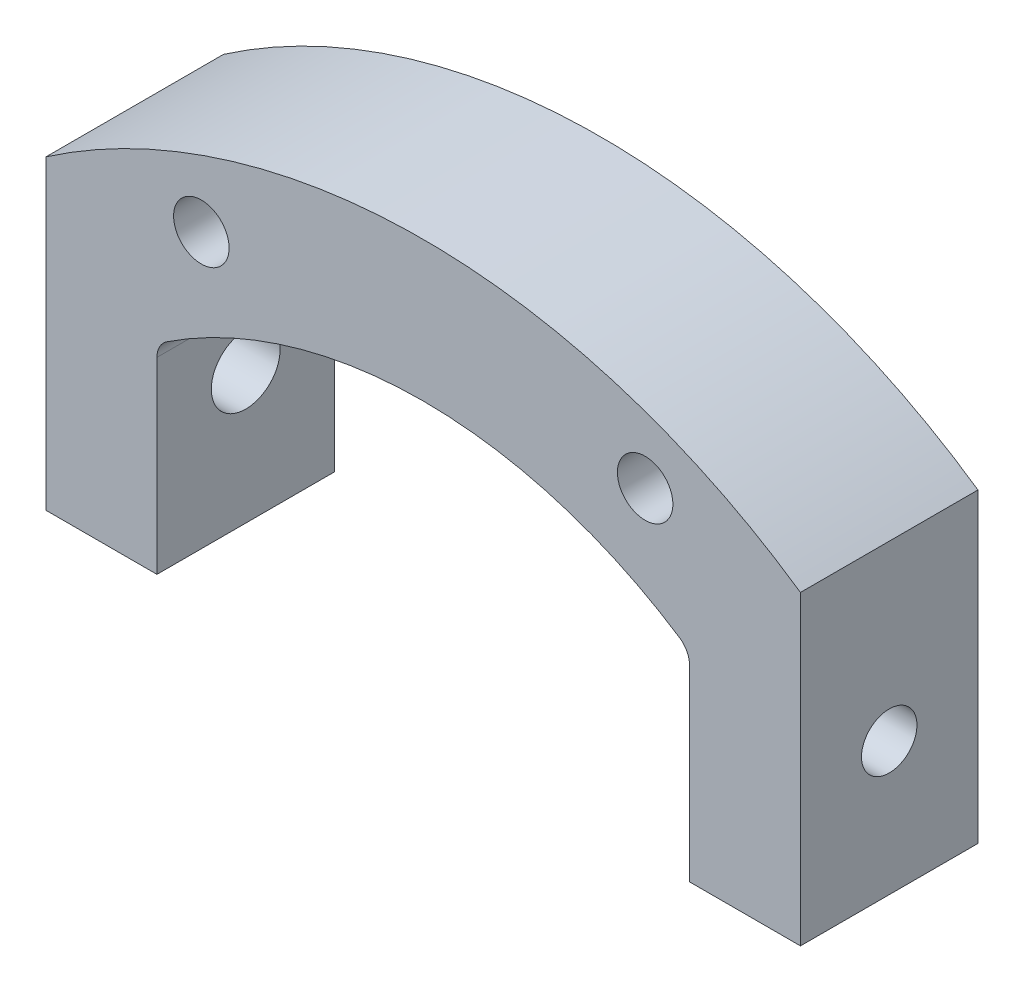
from build123d import *

# Parameters (mm, degrees)
SKETCH_4_R          = 1.25
EXTRUDE_2_DEPTH     = 8
SKETCH_5_W          = 4.5
SKETCH_5_H          = 18.121653049
CUT_EXTRUDE_2_DEPTH = 9
SKETCH_6_R          = 1.25
CUT_EXTRUDE_3_DEPTH = 35
SKETCH_7_R          = 1.55
CUT_EXTRUDE_4_DEPTH = 6
FILLET_1_R          = 1


with BuildPart() as part:
    # 草图4 → 凸台-拉伸2 (new body)
    with BuildSketch(Plane.XY):
        with BuildLine():
            Line((-21.5, 5), (-21.5, -5))
            Line((-21.5, -5), (21.5, -5))
            Line((21.5, -5), (21.5, 5))
            ThreePointArc((21.5, 5), (0, 14.077524047), (-21.5, 5))
        make_face()
        with Locations((-10, 9.361795295)):
            Circle(SKETCH_4_R, mode=Mode.SUBTRACT)
        with Locations((10, 9.361795295)):
            Circle(SKETCH_4_R, mode=Mode.SUBTRACT)
    extrude(amount=EXTRUDE_2_DEPTH)

    # 草图5 → 切除-拉伸2 (cut, through all)
    with BuildSketch(Plane.XY.offset(8)):
        with BuildLine():
            Line((-12, 4), (-12, -5))
            Line((-12, -5), (12, -5))
            Line((12, -5), (12, 4))
            ThreePointArc((12, 4), (0, 7.76631206), (-12, 4))
        make_face()
        with Locations((19.25, 4.060826525)):
            Rectangle(SKETCH_5_W, SKETCH_5_H)
        with Locations((-19.25, 4.060826525)):
            Rectangle(SKETCH_5_W, SKETCH_5_H)
    extrude(amount=-CUT_EXTRUDE_2_DEPTH, mode=Mode.SUBTRACT)

    # 草图6 → 切除-拉伸3 (cut, through all)
    with BuildSketch(Plane.ZY.offset(17)):
        with Locations((4, 1)):
            Circle(SKETCH_6_R)
    extrude(amount=-CUT_EXTRUDE_3_DEPTH, mode=Mode.SUBTRACT)

    # 草图7 → 切除-拉伸4 (cut)
    with BuildSketch(Plane.ZY.offset(17)):
        with Locations((4, 1)):
            Circle(SKETCH_7_R)
    extrude(amount=-CUT_EXTRUDE_4_DEPTH, mode=Mode.SUBTRACT)

    # 圆角1
    fillet_1_edges = [part.edges().sort_by_distance(p)[0] for p in [
        (12, 4, 4),
        (-12, 4, 4),
    ]]
    fillet(fillet_1_edges, radius=FILLET_1_R)


solid = part.part
